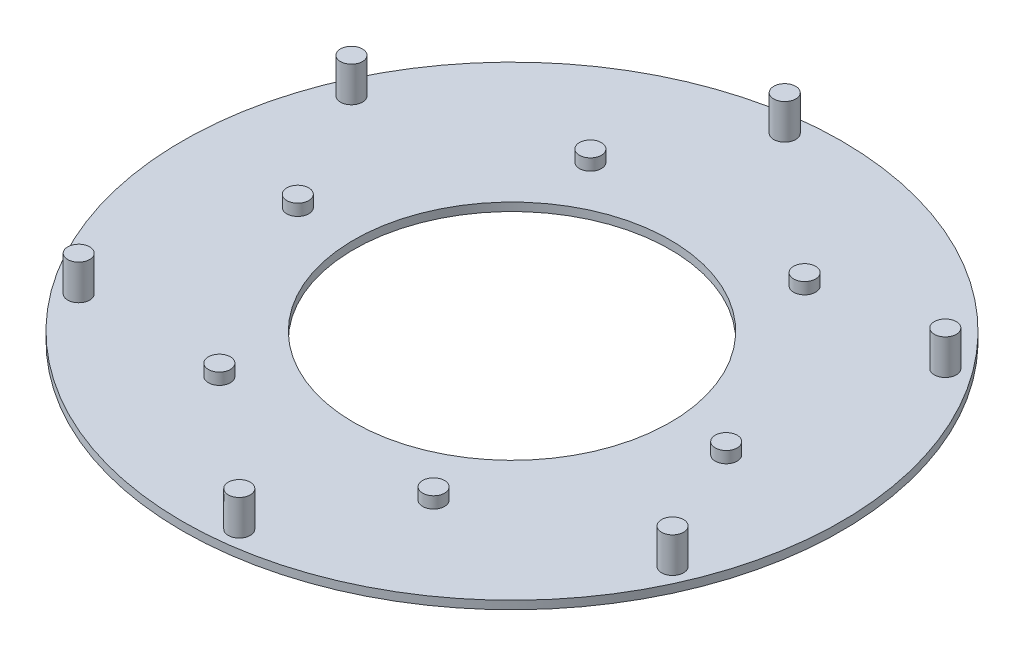
from build123d import *

# Parameters (mm, degrees)
SKETCH1_R           = 200
SKETCH1_R_2         = 96
BOSS_EXTRUDE1_DEPTH = 5
SKETCH2_R           = 3.5
SKETCH2_R_2         = 2
CUT_EXTRUDE1_DEPTH  = 5
CIRPATTERN1_COUNT   = 6
SCALE2_SCALE        = 0.225
SKETCH3_R           = 1.5
BOSS_EXTRUDE2_DEPTH = 5.93
SKETCH4_R           = 1.5
BOSS_EXTRUDE3_DEPTH = 2.7
CIRPATTERN2_COUNT   = 6


with BuildPart() as part:
    # Sketch1 → Boss-Extrude1 (new body)
    with BuildSketch(Plane(origin=(0, 0, 0), x_dir=(1, 0, 0), z_dir=(0, 1, 0))):
        Circle(SKETCH1_R)
        Circle(SKETCH1_R_2, mode=Mode.SUBTRACT)
    extrude(amount=BOSS_EXTRUDE1_DEPTH)

    # Sketch2 → Cut-Extrude1 (cut)
    with BuildSketch(Plane(origin=(0, 5, 0), x_dir=(1, 0, 0), z_dir=(0, 1, 0))):
        with Locations((151.125089796, 111.826683909)):
            Circle(SKETCH2_R)
        with Locations((130, 0)):
            Circle(SKETCH2_R_2)
    cut_extrude1 = extrude(amount=-CUT_EXTRUDE1_DEPTH, mode=Mode.SUBTRACT)

    # CirPattern1: Cut-Extrude1 ×6 about axis
    cirpattern1_axis = Axis((0, 0, 0), (0, 1, 0))
    for i in range(1, CIRPATTERN1_COUNT):
        add(cut_extrude1.rotate(cirpattern1_axis, i * 360 / CIRPATTERN1_COUNT), mode=Mode.SUBTRACT)


with BuildPart() as part_1:
    # Scale2: scaled about (0, 2.5, 0)
    add(part.part.scale(SCALE2_SCALE).moved(Location((0, 1.9375, 0))))

    # Sketch3 → Boss-Extrude2 (add)
    with BuildSketch(Plane.XZ.offset(-1.9375)):
        with Locations((-38.791641146, -16.867085616)):
            Circle(SKETCH3_R)
    boss_extrude2 = extrude(amount=-BOSS_EXTRUDE2_DEPTH)

    # Sketch4 → Boss-Extrude3 (add)
    with BuildSketch(Plane.XZ.offset(-1.9375)):
        with Locations((-14.625, 25.331243061)):
            Circle(SKETCH4_R)
        with Locations((14.625, 25.331243061)):
            Circle(SKETCH4_R)
        with Locations((29.25, 0)):
            Circle(SKETCH4_R)
        with Locations((14.625, -25.331243061)):
            Circle(SKETCH4_R)
        with Locations((-14.625, -25.331243061)):
            Circle(SKETCH4_R)
        with Locations((-29.25, 0)):
            Circle(SKETCH4_R)
    extrude(amount=-BOSS_EXTRUDE3_DEPTH)

    # CirPattern2: Boss-Extrude2 ×6 about axis
    cirpattern2_axis = Axis((0, 0, 0), (0, 1, 0))
    for i in range(1, CIRPATTERN2_COUNT):
        add(boss_extrude2.rotate(cirpattern2_axis, i * 360 / CIRPATTERN2_COUNT))


solid = part_1.part
